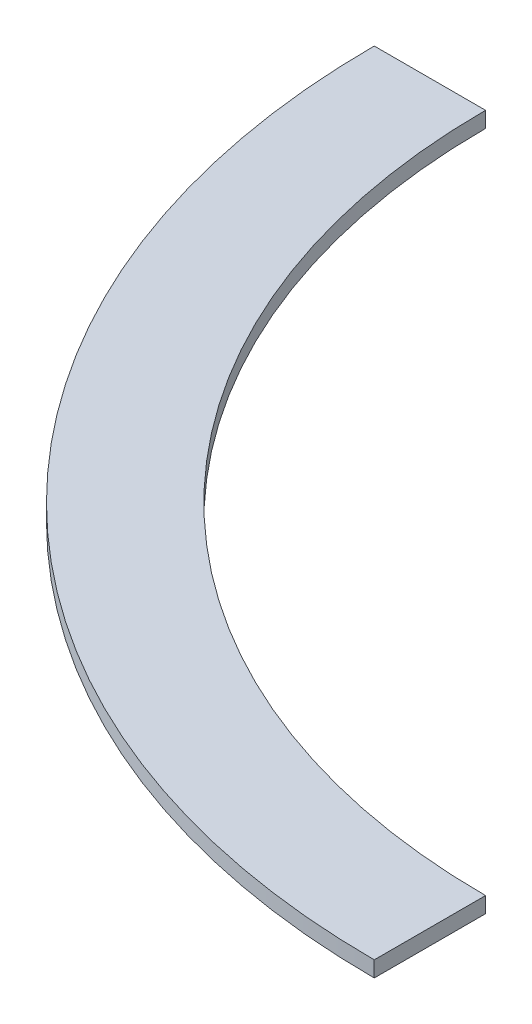
from build123d import *

# Parameters (mm, degrees)
BOSS_EXTRUDE1_DEPTH = 7.9375


with BuildPart() as part:
    # Sketch1 → Boss-Extrude1 (new body)
    with BuildSketch(Plane(origin=(0, 0, 0), x_dir=(1, 0, 0), z_dir=(0, 1, 0))):
        with BuildLine():
            Line((0, -399.0975), (0, -342.9635))
            ThreePointArc((0, -342.9635), (-242.511816549, -242.511816549), (-342.9635, 0))
            Line((-342.9635, 0), (-399.0975, 0))
            ThreePointArc((-399.0975, 0), (-282.204548605, -282.204548605), (0, -399.0975))
        make_face()
    extrude(amount=BOSS_EXTRUDE1_DEPTH)


solid = part.part
